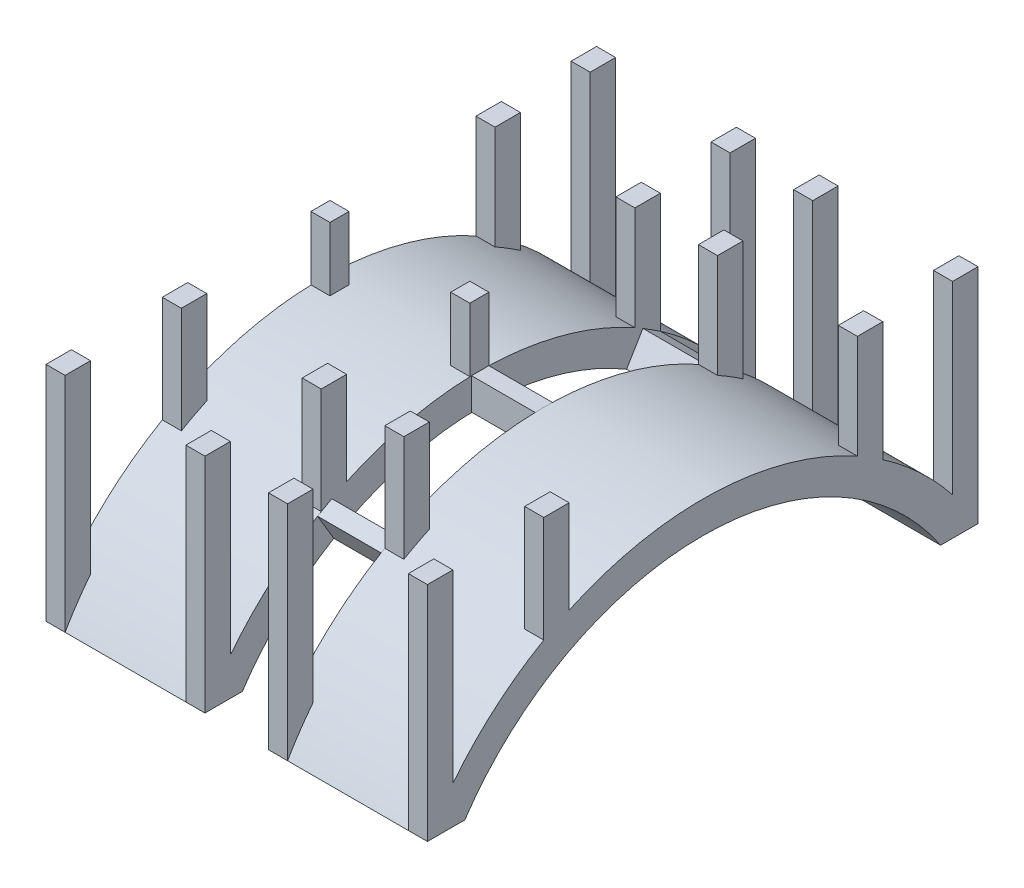
from build123d import *

# Parameters (mm, degrees)
BOSS_EXTRUDE1_DEPTH   = 25
SKETCH5_W             = 2.728546834
SKETCH5_H             = 9.92553646
BOSS_EXTRUDE3_DEPTH   = 10
BOSS_EXTRUDE4_DEPTH   = 10
BOSS_EXTRUDE5_START   = -50
SKETCH7_W             = 6
SKETCH7_H             = 8
BOSS_EXTRUDE5_DEPTH   = 70
BOSS_EXTRUDE6_START   = -50
SKETCH7_3_W           = 6
SKETCH7_3_H           = 8
BOSS_EXTRUDE6_DEPTH   = 70
BOSS_EXTRUDE7_START   = -19
SKETCH7_4_W           = 6
SKETCH7_4_H           = 8
BOSS_EXTRUDE7_DEPTH   = 39
SKETCH7_5_W           = 6
SKETCH7_5_H           = 6
BOSS_EXTRUDE8_DEPTH   = 20
BOSS_EXTRUDE8_2_DEPTH = 20
BOSS_EXTRUDE9_START   = -24
SKETCH7_6_W           = 6
SKETCH7_6_H           = 8
BOSS_EXTRUDE9_DEPTH   = 44
BOSS_EXTRUDE10_START  = -50
SKETCH7_7_W           = 6
SKETCH7_7_H           = 8
BOSS_EXTRUDE10_DEPTH  = 70


with BuildPart() as part:
    # Sketch2 → Boss-Extrude1 (new, symmetric)
    with BuildSketch(Plane(origin=(0, 0, 0), x_dir=(0, 0, -1), z_dir=(1, 0, 0))):
        with BuildLine():
            Line((74.833147735, 0), (86.602540378, 0))
            ThreePointArc((86.602540378, 0), (0, 50), (-86.602540378, 0))
            Line((-86.602540378, 0), (-74.833147735, 0))
            ThreePointArc((-74.833147735, 0), (0, 40), (74.833147735, 0))
        make_face()
    boss_extrude1 = extrude(amount=BOSS_EXTRUDE1_DEPTH, both=True)

    # Sketch5 → Boss-Extrude3 (add)
    with BuildSketch(Plane(origin=(25, 0, 0), x_dir=(0, 0, -1), z_dir=(1, 0, 0))):
        with Locations((-1.364273417, 45)):
            Rectangle(SKETCH5_W, SKETCH5_H)
        with Locations((1.364273417, 45)):
            Rectangle(SKETCH5_W, SKETCH5_H)
    boss_extrude3 = extrude(amount=BOSS_EXTRUDE3_DEPTH)

    # Sketch6 → Boss-Extrude4 (add)
    with BuildSketch(Plane(origin=(25, 0, 0), x_dir=(0, 0, -1), z_dir=(1, 0, 0))):
        Polygon((-51.176951237, 35.912278878), (-46.059256113, 27.321050991), (-42.017037291, 29.590002999), (-46.68559699, 38.433336665), align=None)
        Polygon((46.059256113, 27.321050991), (51.176951237, 35.912278878), (56.654177251, 32.403302118), (50.988759526, 24.162971906), align=None)
    boss_extrude4 = extrude(amount=BOSS_EXTRUDE4_DEPTH)

    # Sketch7 → Boss-Extrude5 (add)
    with BuildSketch(Plane(origin=(0, 50, 0), x_dir=(1, 0, 0), z_dir=(0, 1, 0)).offset(BOSS_EXTRUDE5_START)):
        with Locations((22, -82.602540378)):
            Rectangle(SKETCH7_W, SKETCH7_H)
    boss_extrude5 = extrude(amount=BOSS_EXTRUDE5_DEPTH)

    # Sketch7_3 → Boss-Extrude6 (add)
    with BuildSketch(Plane(origin=(0, 50, 0), x_dir=(1, 0, 0), z_dir=(0, 1, 0)).offset(BOSS_EXTRUDE6_START)):
        with Locations((-22, -82.602540378)):
            Rectangle(SKETCH7_3_W, SKETCH7_3_H)
    boss_extrude6 = extrude(amount=BOSS_EXTRUDE6_DEPTH)

    # Sketch7_4 → Boss-Extrude7 (add)
    with BuildSketch(Plane(origin=(0, 50, 0), x_dir=(1, 0, 0), z_dir=(0, 1, 0)).offset(BOSS_EXTRUDE7_START)):
        with Locations((22, -46.017037291)):
            Rectangle(SKETCH7_4_W, SKETCH7_4_H)
        with Locations((-22, -46.017037291)):
            Rectangle(SKETCH7_4_W, SKETCH7_4_H)
    boss_extrude7 = extrude(amount=BOSS_EXTRUDE7_DEPTH)

    # Sketch7_6 → Boss-Extrude9 (add)
    with BuildSketch(Plane(origin=(0, 50, 0), x_dir=(1, 0, 0), z_dir=(0, 1, 0)).offset(BOSS_EXTRUDE9_START)):
        with Locations((22, 52.654177251)):
            Rectangle(SKETCH7_6_W, SKETCH7_6_H)
        with Locations((-22, 52.654177251)):
            Rectangle(SKETCH7_6_W, SKETCH7_6_H)
    boss_extrude9 = extrude(amount=BOSS_EXTRUDE9_DEPTH)

    # Sketch7_7 → Boss-Extrude10 (add)
    with BuildSketch(Plane(origin=(0, 50, 0), x_dir=(1, 0, 0), z_dir=(0, 1, 0)).offset(BOSS_EXTRUDE10_START)):
        with Locations((22, 82.602540378)):
            Rectangle(SKETCH7_7_W, SKETCH7_7_H)
        with Locations((-22, 82.602540378)):
            Rectangle(SKETCH7_7_W, SKETCH7_7_H)
    boss_extrude10 = extrude(amount=BOSS_EXTRUDE10_DEPTH)

    # Mirror7: Boss-Extrude1, Boss-Extrude3, Boss-Extrude4, Boss-Extrude5, Boss-Extrude6, Boss-Extrude7, Boss-Extrude9, Boss-Extrude10 across plane
    add(boss_extrude1.mirror(Plane(origin=(35, 0, 0), x_dir=(0, 0, 1), z_dir=(1, 0, 0))))
    add(boss_extrude3.mirror(Plane(origin=(35, 0, 0), x_dir=(0, 0, 1), z_dir=(1, 0, 0))))
    add(boss_extrude4.mirror(Plane(origin=(35, 0, 0), x_dir=(0, 0, 1), z_dir=(1, 0, 0))))
    add(boss_extrude5.mirror(Plane(origin=(35, 0, 0), x_dir=(0, 0, 1), z_dir=(1, 0, 0))))
    add(boss_extrude6.mirror(Plane(origin=(35, 0, 0), x_dir=(0, 0, 1), z_dir=(1, 0, 0))))
    add(boss_extrude7.mirror(Plane(origin=(35, 0, 0), x_dir=(0, 0, 1), z_dir=(1, 0, 0))))
    add(boss_extrude9.mirror(Plane(origin=(35, 0, 0), x_dir=(0, 0, 1), z_dir=(1, 0, 0))))
    add(boss_extrude10.mirror(Plane(origin=(35, 0, 0), x_dir=(0, 0, 1), z_dir=(1, 0, 0))))


with BuildPart() as body_2:
    # Sketch7_5 → Boss-Extrude8 (new body)
    with BuildSketch(Plane(origin=(0, 50, 0), x_dir=(1, 0, 0), z_dir=(0, 1, 0))):
        with Locations((22, -0.271453166)):
            Rectangle(SKETCH7_5_W, SKETCH7_5_H)
    extrude(amount=BOSS_EXTRUDE8_DEPTH)


with BuildPart() as body_3:
    # Sketch7_5 → Boss-Extrude8 2 (new body)
    with BuildSketch(Plane(origin=(0, 50, 0), x_dir=(1, 0, 0), z_dir=(0, 1, 0))):
        with Locations((-22, -0.271453166)):
            Rectangle(SKETCH7_5_W, SKETCH7_5_H)
    extrude(amount=BOSS_EXTRUDE8_2_DEPTH)


solid = Compound([part.part, body_2.part, body_3.part])
